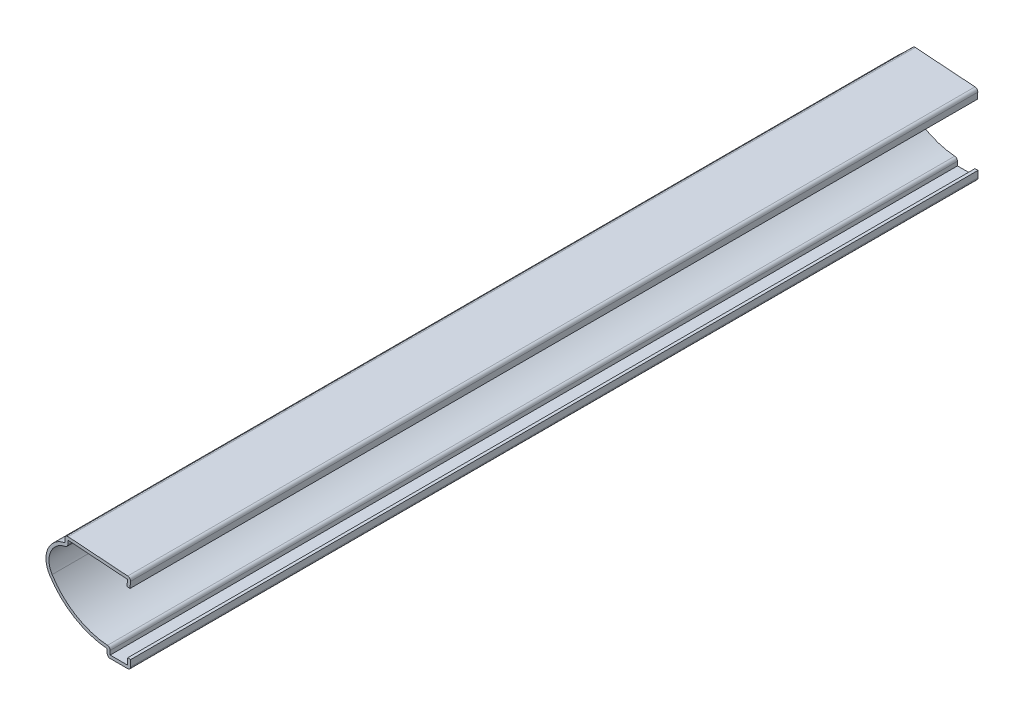
from build123d import *

# Parameters (mm, degrees)
EXTRUDE_THIN1_DEPTH = 285.75
FILLET1_R           = 1.016


with BuildPart() as part:
    # Sketch1 → Extrude-Thin1 (new body)
    with BuildSketch(Plane.XY):
        with BuildLine():
            Line((0, 3.175), (0, 0))
            Line((0, 0), (-7.9375, 0))
            Line((-7.9375, 0), (-7.9375, 2.38125))
            ThreePointArc((-7.9375, 2.38125), (-19.045912437, 5.99541523), (-27.361917214, 14.199260776))
            ThreePointArc((-27.361917214, 14.199260776), (-27.934001551, 21.541515485), (-22.225, 26.19375))
            Line((-22.225, 26.19375), (-22.225, 28.575))
            Line((-22.225, 28.575), (0, 26.9875))
            Line((0, 26.9875), (-0.226785714, 23.8125))
            Line((-0.226785714, 23.8125), (-1.240203753, 23.884887003))
            Line((-1.240203753, 23.884887003), (-1.085805042, 26.046468964))
            Line((-1.085805042, 26.046468964), (-21.209, 27.483840032))
            Line((-21.209, 27.483840032), (-21.209, 25.314485679))
            ThreePointArc((-21.209, 25.314485679), (-26.827226174, 21.514111333), (-26.50119181, 14.739082765))
            ThreePointArc((-26.50119181, 14.739082765), (-18.11648679, 6.624447995), (-6.9215, 3.334638499))
            Line((-6.9215, 3.334638499), (-6.9215, 1.016))
            Line((-6.9215, 1.016), (-1.016, 1.016))
            Line((-1.016, 1.016), (-1.016, 3.175))
            Line((-1.016, 3.175), (0, 3.175))
        make_face()
    extrude(amount=-EXTRUDE_THIN1_DEPTH)

    # Fillet1
    fillet1_edges = [part.edges().sort_by_distance(p)[0] for p in [
        (-21.209, 25.314485679, -142.875),
        (-6.9215, 3.334638499, -142.875),
        (0, 0, -142.875),
        (-7.9375, 0, -142.875),
        (-22.225, 28.575, -142.875),
        (0, 26.9875, -142.875),
    ]]
    fillet(fillet1_edges, radius=FILLET1_R)


solid = part.part
